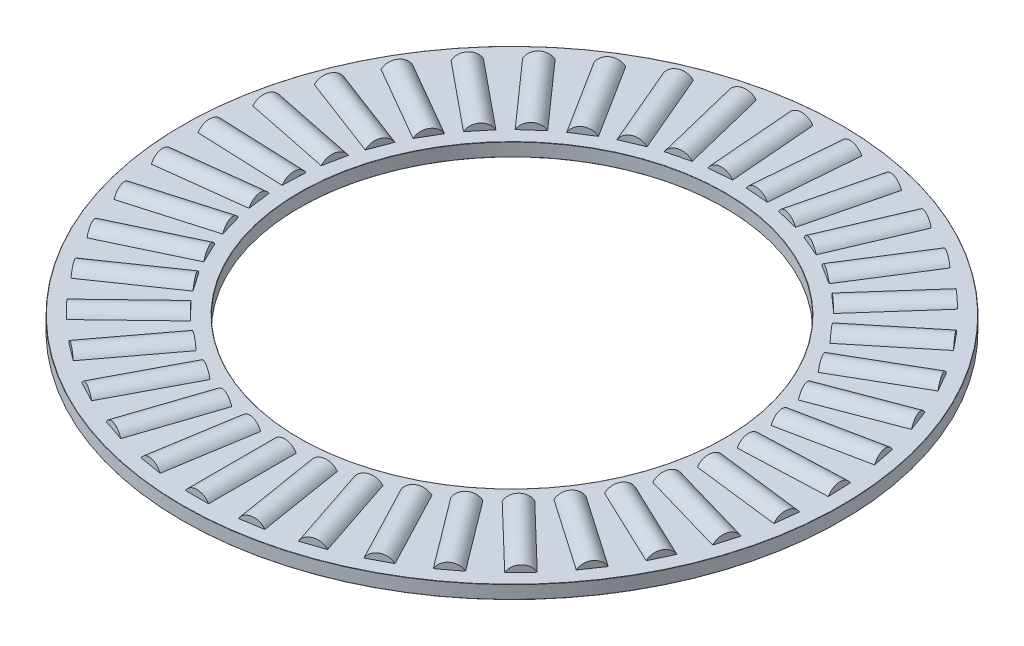
from build123d import *

# Parameters (mm, degrees)
SKETCH1_W         = 8.73125
SKETCH1_H         = 0.9921875
SKETCH3_W         = 6.5484375
SKETCH3_H         = 0.9921875
SKETCH2_W         = 6.5484375
SKETCH2_H         = 0.9921875
CIRPATTERN1_COUNT = 39
CIRPATTERN1_ANGLE = 350.769230769
CIRPATTERN2_COUNT = 39
FILLET2_R         = 0.01984375


with BuildPart() as part:
    # Sketch1 → Revolve1 (revolve)
    with BuildSketch(Plane(origin=(0, 0, 0), x_dir=(0, 0, -1), z_dir=(1, 0, 0)), mode=Mode.PRIVATE) as revolve1_sk:
        with Locations((-20.240625, 0)):
            Rectangle(SKETCH1_W, SKETCH1_H)
    revolve(revolve1_sk.sketch.rotate(Axis((0, -0.9921875, 0), (0, 1, 0)), 180), axis=Axis((0, -0.9921875, 0), (0, 1, 0)))

    # Sketch3 → Cut-Revolve1 (revolve, cut)
    with BuildSketch(Plane(origin=(0, 0, 0), x_dir=(0, 0, -1), z_dir=(1, 0, 0))):
        with Locations((-20.240625, 0.49609375)):
            Rectangle(SKETCH3_W, SKETCH3_H)
    cut_revolve1 = revolve(axis=Axis((0, 0, 23.51484375), (0, 0, -1)), mode=Mode.SUBTRACT)

    # CirPattern2: Cut-Revolve1 ×39 about axis
    cirpattern2_axis = Axis((0, 0, 0), (0, 1, 0))
    for i in range(1, CIRPATTERN2_COUNT):
        add(cut_revolve1.rotate(cirpattern2_axis, i * 360 / CIRPATTERN2_COUNT), mode=Mode.SUBTRACT)

    # Fillet2
    fillet2_edges = [part.edges().sort_by_distance(p)[0] for p in [
        (0, 0.49609375, 24.60625),
        (0, 0.49609375, 15.875),
        (0, -0.49609375, 15.875),
        (0, -0.49609375, 24.60625),
    ]]
    fillet(fillet2_edges, radius=FILLET2_R)


with BuildPart() as body_2:
    # Sketch2 → Revolve2 (revolve)
    with BuildSketch(Plane(origin=(0, 0, 0), x_dir=(0, 0, -1), z_dir=(1, 0, 0)), mode=Mode.PRIVATE) as revolve2_sk:
        with Locations((-20.240625, 0.49609375)):
            Rectangle(SKETCH2_W, SKETCH2_H)
    revolve(revolve2_sk.sketch.rotate(Axis((0, 0, 23.51484375), (0, 0, -1)), 90), axis=Axis((0, 0, 23.51484375), (0, 0, -1)))


with BuildPart() as cirpattern1_1:
    # CirPattern1: pattern copy
    add(body_2.part.rotate(Axis((0, 0.9921875, 0), (0, -1, 0)), 1 * CIRPATTERN1_ANGLE / (CIRPATTERN1_COUNT - 1)))


with BuildPart() as cirpattern1_2:
    # CirPattern1: pattern copy
    add(body_2.part.rotate(Axis((0, 0.9921875, 0), (0, -1, 0)), 2 * CIRPATTERN1_ANGLE / (CIRPATTERN1_COUNT - 1)))


with BuildPart() as cirpattern1_3:
    # CirPattern1: pattern copy
    add(body_2.part.rotate(Axis((0, 0.9921875, 0), (0, -1, 0)), 3 * CIRPATTERN1_ANGLE / (CIRPATTERN1_COUNT - 1)))


with BuildPart() as cirpattern1_4:
    # CirPattern1: pattern copy
    add(body_2.part.rotate(Axis((0, 0.9921875, 0), (0, -1, 0)), 4 * CIRPATTERN1_ANGLE / (CIRPATTERN1_COUNT - 1)))


with BuildPart() as cirpattern1_5:
    # CirPattern1: pattern copy
    add(body_2.part.rotate(Axis((0, 0.9921875, 0), (0, -1, 0)), 5 * CIRPATTERN1_ANGLE / (CIRPATTERN1_COUNT - 1)))


with BuildPart() as cirpattern1_6:
    # CirPattern1: pattern copy
    add(body_2.part.rotate(Axis((0, 0.9921875, 0), (0, -1, 0)), 6 * CIRPATTERN1_ANGLE / (CIRPATTERN1_COUNT - 1)))


with BuildPart() as cirpattern1_7:
    # CirPattern1: pattern copy
    add(body_2.part.rotate(Axis((0, 0.9921875, 0), (0, -1, 0)), 7 * CIRPATTERN1_ANGLE / (CIRPATTERN1_COUNT - 1)))


with BuildPart() as cirpattern1_8:
    # CirPattern1: pattern copy
    add(body_2.part.rotate(Axis((0, 0.9921875, 0), (0, -1, 0)), 8 * CIRPATTERN1_ANGLE / (CIRPATTERN1_COUNT - 1)))


with BuildPart() as cirpattern1_9:
    # CirPattern1: pattern copy
    add(body_2.part.rotate(Axis((0, 0.9921875, 0), (0, -1, 0)), 9 * CIRPATTERN1_ANGLE / (CIRPATTERN1_COUNT - 1)))


with BuildPart() as cirpattern1_10:
    # CirPattern1: pattern copy
    add(body_2.part.rotate(Axis((0, 0.9921875, 0), (0, -1, 0)), 10 * CIRPATTERN1_ANGLE / (CIRPATTERN1_COUNT - 1)))


with BuildPart() as cirpattern1_11:
    # CirPattern1: pattern copy
    add(body_2.part.rotate(Axis((0, 0.9921875, 0), (0, -1, 0)), 11 * CIRPATTERN1_ANGLE / (CIRPATTERN1_COUNT - 1)))


with BuildPart() as cirpattern1_12:
    # CirPattern1: pattern copy
    add(body_2.part.rotate(Axis((0, 0.9921875, 0), (0, -1, 0)), 12 * CIRPATTERN1_ANGLE / (CIRPATTERN1_COUNT - 1)))


with BuildPart() as cirpattern1_13:
    # CirPattern1: pattern copy
    add(body_2.part.rotate(Axis((0, 0.9921875, 0), (0, -1, 0)), 13 * CIRPATTERN1_ANGLE / (CIRPATTERN1_COUNT - 1)))


with BuildPart() as cirpattern1_14:
    # CirPattern1: pattern copy
    add(body_2.part.rotate(Axis((0, 0.9921875, 0), (0, -1, 0)), 14 * CIRPATTERN1_ANGLE / (CIRPATTERN1_COUNT - 1)))


with BuildPart() as cirpattern1_15:
    # CirPattern1: pattern copy
    add(body_2.part.rotate(Axis((0, 0.9921875, 0), (0, -1, 0)), 15 * CIRPATTERN1_ANGLE / (CIRPATTERN1_COUNT - 1)))


with BuildPart() as cirpattern1_16:
    # CirPattern1: pattern copy
    add(body_2.part.rotate(Axis((0, 0.9921875, 0), (0, -1, 0)), 16 * CIRPATTERN1_ANGLE / (CIRPATTERN1_COUNT - 1)))


with BuildPart() as cirpattern1_17:
    # CirPattern1: pattern copy
    add(body_2.part.rotate(Axis((0, 0.9921875, 0), (0, -1, 0)), 17 * CIRPATTERN1_ANGLE / (CIRPATTERN1_COUNT - 1)))


with BuildPart() as cirpattern1_18:
    # CirPattern1: pattern copy
    add(body_2.part.rotate(Axis((0, 0.9921875, 0), (0, -1, 0)), 18 * CIRPATTERN1_ANGLE / (CIRPATTERN1_COUNT - 1)))


with BuildPart() as cirpattern1_19:
    # CirPattern1: pattern copy
    add(body_2.part.rotate(Axis((0, 0.9921875, 0), (0, -1, 0)), 19 * CIRPATTERN1_ANGLE / (CIRPATTERN1_COUNT - 1)))


with BuildPart() as cirpattern1_20:
    # CirPattern1: pattern copy
    add(body_2.part.rotate(Axis((0, 0.9921875, 0), (0, -1, 0)), 20 * CIRPATTERN1_ANGLE / (CIRPATTERN1_COUNT - 1)))


with BuildPart() as cirpattern1_21:
    # CirPattern1: pattern copy
    add(body_2.part.rotate(Axis((0, 0.9921875, 0), (0, -1, 0)), 21 * CIRPATTERN1_ANGLE / (CIRPATTERN1_COUNT - 1)))


with BuildPart() as cirpattern1_22:
    # CirPattern1: pattern copy
    add(body_2.part.rotate(Axis((0, 0.9921875, 0), (0, -1, 0)), 22 * CIRPATTERN1_ANGLE / (CIRPATTERN1_COUNT - 1)))


with BuildPart() as cirpattern1_23:
    # CirPattern1: pattern copy
    add(body_2.part.rotate(Axis((0, 0.9921875, 0), (0, -1, 0)), 23 * CIRPATTERN1_ANGLE / (CIRPATTERN1_COUNT - 1)))


with BuildPart() as cirpattern1_24:
    # CirPattern1: pattern copy
    add(body_2.part.rotate(Axis((0, 0.9921875, 0), (0, -1, 0)), 24 * CIRPATTERN1_ANGLE / (CIRPATTERN1_COUNT - 1)))


with BuildPart() as cirpattern1_25:
    # CirPattern1: pattern copy
    add(body_2.part.rotate(Axis((0, 0.9921875, 0), (0, -1, 0)), 25 * CIRPATTERN1_ANGLE / (CIRPATTERN1_COUNT - 1)))


with BuildPart() as cirpattern1_26:
    # CirPattern1: pattern copy
    add(body_2.part.rotate(Axis((0, 0.9921875, 0), (0, -1, 0)), 26 * CIRPATTERN1_ANGLE / (CIRPATTERN1_COUNT - 1)))


with BuildPart() as cirpattern1_27:
    # CirPattern1: pattern copy
    add(body_2.part.rotate(Axis((0, 0.9921875, 0), (0, -1, 0)), 27 * CIRPATTERN1_ANGLE / (CIRPATTERN1_COUNT - 1)))


with BuildPart() as cirpattern1_28:
    # CirPattern1: pattern copy
    add(body_2.part.rotate(Axis((0, 0.9921875, 0), (0, -1, 0)), 28 * CIRPATTERN1_ANGLE / (CIRPATTERN1_COUNT - 1)))


with BuildPart() as cirpattern1_29:
    # CirPattern1: pattern copy
    add(body_2.part.rotate(Axis((0, 0.9921875, 0), (0, -1, 0)), 29 * CIRPATTERN1_ANGLE / (CIRPATTERN1_COUNT - 1)))


with BuildPart() as cirpattern1_30:
    # CirPattern1: pattern copy
    add(body_2.part.rotate(Axis((0, 0.9921875, 0), (0, -1, 0)), 30 * CIRPATTERN1_ANGLE / (CIRPATTERN1_COUNT - 1)))


with BuildPart() as cirpattern1_31:
    # CirPattern1: pattern copy
    add(body_2.part.rotate(Axis((0, 0.9921875, 0), (0, -1, 0)), 31 * CIRPATTERN1_ANGLE / (CIRPATTERN1_COUNT - 1)))


with BuildPart() as cirpattern1_32:
    # CirPattern1: pattern copy
    add(body_2.part.rotate(Axis((0, 0.9921875, 0), (0, -1, 0)), 32 * CIRPATTERN1_ANGLE / (CIRPATTERN1_COUNT - 1)))


with BuildPart() as cirpattern1_33:
    # CirPattern1: pattern copy
    add(body_2.part.rotate(Axis((0, 0.9921875, 0), (0, -1, 0)), 33 * CIRPATTERN1_ANGLE / (CIRPATTERN1_COUNT - 1)))


with BuildPart() as cirpattern1_34:
    # CirPattern1: pattern copy
    add(body_2.part.rotate(Axis((0, 0.9921875, 0), (0, -1, 0)), 34 * CIRPATTERN1_ANGLE / (CIRPATTERN1_COUNT - 1)))


with BuildPart() as cirpattern1_35:
    # CirPattern1: pattern copy
    add(body_2.part.rotate(Axis((0, 0.9921875, 0), (0, -1, 0)), 35 * CIRPATTERN1_ANGLE / (CIRPATTERN1_COUNT - 1)))


with BuildPart() as cirpattern1_36:
    # CirPattern1: pattern copy
    add(body_2.part.rotate(Axis((0, 0.9921875, 0), (0, -1, 0)), 36 * CIRPATTERN1_ANGLE / (CIRPATTERN1_COUNT - 1)))


with BuildPart() as cirpattern1_37:
    # CirPattern1: pattern copy
    add(body_2.part.rotate(Axis((0, 0.9921875, 0), (0, -1, 0)), 37 * CIRPATTERN1_ANGLE / (CIRPATTERN1_COUNT - 1)))


with BuildPart() as cirpattern1_38:
    # CirPattern1: pattern copy
    add(body_2.part.rotate(Axis((0, 0.9921875, 0), (0, -1, 0)), 38 * CIRPATTERN1_ANGLE / (CIRPATTERN1_COUNT - 1)))


solid = Compound([part.part, body_2.part, cirpattern1_1.part, cirpattern1_2.part, cirpattern1_3.part, cirpattern1_4.part, cirpattern1_5.part, cirpattern1_6.part, cirpattern1_7.part, cirpattern1_8.part, cirpattern1_9.part, cirpattern1_10.part, cirpattern1_11.part, cirpattern1_12.part, cirpattern1_13.part, cirpattern1_14.part, cirpattern1_15.part, cirpattern1_16.part, cirpattern1_17.part, cirpattern1_18.part, cirpattern1_19.part, cirpattern1_20.part, cirpattern1_21.part, cirpattern1_22.part, cirpattern1_23.part, cirpattern1_24.part, cirpattern1_25.part, cirpattern1_26.part, cirpattern1_27.part, cirpattern1_28.part, cirpattern1_29.part, cirpattern1_30.part, cirpattern1_31.part, cirpattern1_32.part, cirpattern1_33.part, cirpattern1_34.part, cirpattern1_35.part, cirpattern1_36.part, cirpattern1_37.part, cirpattern1_38.part])
